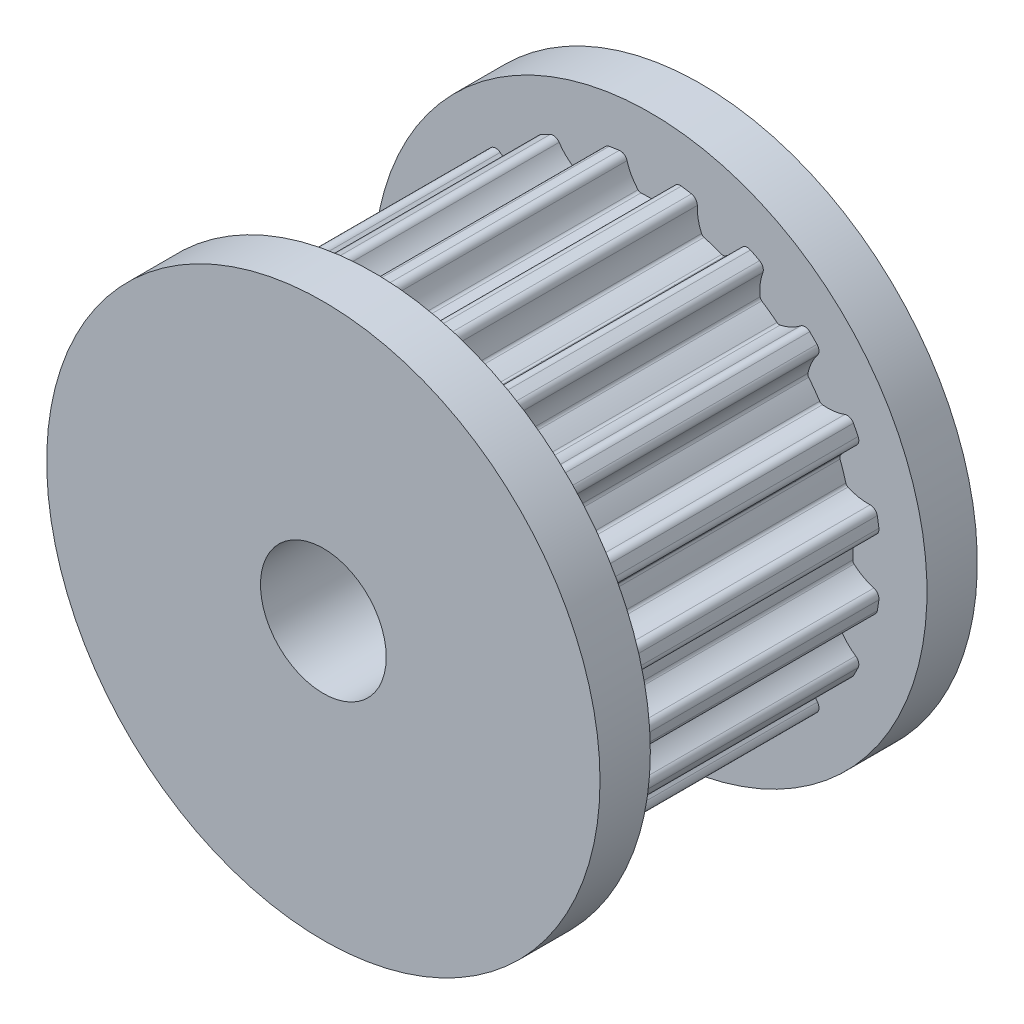
from build123d import *

# Parameters (mm, degrees)
SKETCH_1_R               = 9.17
EXTRUDE_1_DEPTH          = 5.5
CUT_EXTRUDE_START        = -12
CUT_EXTRUDE_1_DEPTH      = 13
PATTERN_CIRCULAR_1_COUNT = 20
SKETCH_3_R               = 11
EXTRUDE_2_DEPTH          = 2
SKETCH_9_R               = 11
EXTRUDE_3_DEPTH          = 2
SKETCH_4_R               = 2.5
CUT_EXTRUDE_2_DEPTH      = 16
SKETCH_10_R              = 2
CUT_EXTRUDE_3_DEPTH      = 12
SKETCH_11_R              = 2
CUT_EXTRUDE_4_DEPTH      = 12


with BuildPart() as part:
    # 草圖1 → 填料-伸長1 (new body, symmetric)
    with BuildSketch(Plane.XY):
        Circle(SKETCH_1_R)
    extrude(amount=EXTRUDE_1_DEPTH, both=True)

    # 草圖2 → 除料-伸長1 (cut)
    with BuildSketch(Plane.XY.offset(5.5).offset(CUT_EXTRUDE_START)):
        with BuildLine():
            ThreePointArc((-0.372835703, 8.051372153), (0, 8.06), (0.372835703, 8.051372153))
            ThreePointArc((0.372835703, 8.051372153), (0.437515299, 8.062770331), (0.491125647, 8.100708427))
            ThreePointArc((0.491125647, 8.100708427), (0.753329245, 8.468226481), (0.925222062, 8.885686787))
            ThreePointArc((0.925222062, 8.885686787), (1.041179318, 9.043582036), (1.232246479, 9.086829404))
            ThreePointArc((1.232246479, 9.086829404), (0, 9.17), (-1.232246479, 9.086829404))
            ThreePointArc((-1.232246479, 9.086829404), (-1.041179318, 9.043582036), (-0.925222062, 8.885686787))
            ThreePointArc((-0.925222062, 8.885686787), (-0.753329245, 8.468226481), (-0.491125647, 8.100708427))
            ThreePointArc((-0.491125647, 8.100708427), (-0.437515299, 8.062770331), (-0.372835703, 8.051372153))
        make_face()
    cut_extrude_1 = extrude(amount=CUT_EXTRUDE_1_DEPTH, mode=Mode.SUBTRACT)

    # 環狀複製排列1: 除料-伸長1 ×20 about axis
    pattern_circular_1_axis = Axis((0, 0, 0), (0, 0, 1))
    for i in range(1, PATTERN_CIRCULAR_1_COUNT):
        add(cut_extrude_1.rotate(pattern_circular_1_axis, i * 360 / PATTERN_CIRCULAR_1_COUNT), mode=Mode.SUBTRACT)

    # 草圖3 → 填料-伸長2 (add)
    with BuildSketch(Plane.XY.offset(5.5)):
        Circle(SKETCH_3_R)
    extrude(amount=EXTRUDE_2_DEPTH)

    # 草圖9 → 填料-伸長3 (add)
    with BuildSketch(Plane(origin=(0, 0, -5.5), x_dir=(-1, 0, 0), z_dir=(0, 0, -1))):
        Circle(SKETCH_9_R)
    extrude(amount=EXTRUDE_3_DEPTH)

    # 草圖4 → 除料-伸長2 (cut, through all)
    with BuildSketch(Plane.XY.offset(7.5)):
        Circle(SKETCH_4_R)
    extrude(amount=-CUT_EXTRUDE_2_DEPTH, mode=Mode.SUBTRACT)

    # 草圖10 → 除料-伸長3 (cut, through all)
    with BuildSketch(Plane(origin=(0, 0, 0), x_dir=(1, 0, 0), z_dir=(0, 1, 0))):
        Circle(SKETCH_10_R)
    extrude(amount=-CUT_EXTRUDE_3_DEPTH, mode=Mode.SUBTRACT)

    # 草圖11 → 除料-伸長4 (cut, through all)
    with BuildSketch(Plane(origin=(0, 0, 0), x_dir=(0, 0, -1), z_dir=(1, 0, 0))):
        Circle(SKETCH_11_R)
    extrude(amount=-CUT_EXTRUDE_4_DEPTH, mode=Mode.SUBTRACT)


solid = part.part
